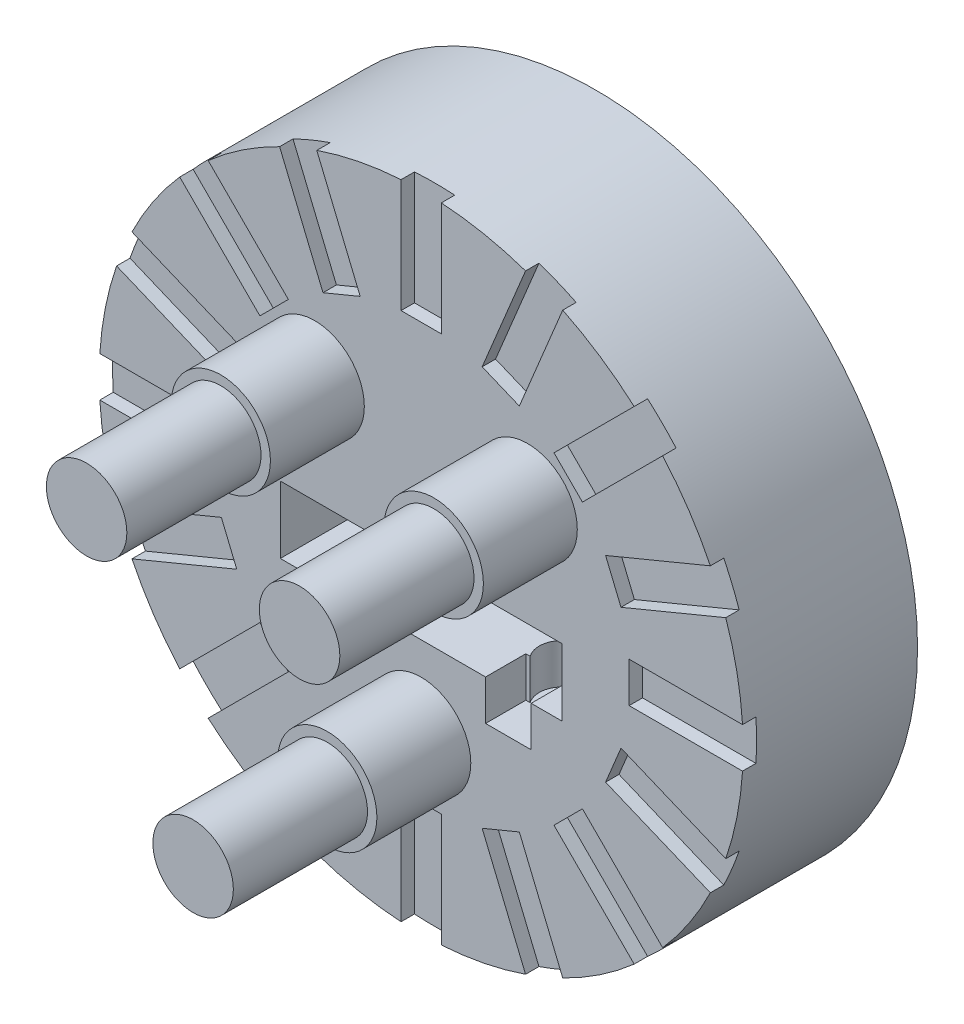
from build123d import *

# Parameters (mm, degrees)
SKETCH1_R           = 24
EXTRUDE1_DEPTH      = 5
SKETCH2_R           = 24
EXTRUDE2_DEPTH      = 8
SKETCH3_R           = 2.5
SKETCH3_R_2         = 3.7
EXTRUDE3_DEPTH      = 7
SKETCH5_R           = 3
EXTRUDE6_DEPTH      = 10
SKETCH6_R           = 3.175
EXTRUDE7_DEPTH      = 3
SKETCH7_R           = 1.7
EXTRUDE8_DEPTH      = 8
EXTRUDE8_DEPTH_BACK = 3
SKETCH8_W           = 3.4
SKETCH8_H           = 3
EXTRUDE9_DEPTH      = 3
EXTRUDE10_DEPTH     = 1


with BuildPart() as part:
    # Sketch1 → Extrude1 (new body)
    with BuildSketch(Plane.XY):
        Circle(SKETCH1_R)
    extrude(amount=EXTRUDE1_DEPTH)

    # Sketch2 → Extrude2 (add)
    with BuildSketch(Plane.XY.offset(5)):
        Circle(SKETCH2_R)
        with BuildLine():
            Line((-2.5, 0), (-10.5, 0))
            Line((-10.5, 0), (-10.5, -5))
            Line((-10.5, -5), (10.5, -5))
            Line((10.5, -5), (10.5, 0))
            Line((10.5, 0), (2.5, 0))
            ThreePointArc((2.5, 0), (0, -2.5), (-2.5, 0))
        make_face(mode=Mode.SUBTRACT)
    extrude(amount=EXTRUDE2_DEPTH)

    # Sketch3 → Extrude3 (add)
    with BuildSketch(Plane.XY.offset(13)):
        Circle(SKETCH3_R)
        with Locations((-7.9375, 7.9375)):
            Circle(SKETCH3_R_2)
        with Locations((7.9375, 7.9375)):
            Circle(SKETCH3_R_2)
        with Locations((0, -11.1125)):
            Circle(SKETCH3_R_2)
    extrude(amount=EXTRUDE3_DEPTH)

    # Sketch5 → Extrude6 (add)
    with BuildSketch(Plane.XY.offset(20)):
        with Locations((-7.9375, 7.9375)):
            Circle(SKETCH5_R)
        with Locations((7.9375, 7.9375)):
            Circle(SKETCH5_R)
        with Locations((0, -11.1125)):
            Circle(SKETCH5_R)
    extrude(amount=EXTRUDE6_DEPTH)

    # Sketch6 → Extrude7 (cut)
    with BuildSketch(Plane(origin=(0, 0, 0), x_dir=(-1, 0, 0), z_dir=(0, 0, -1))):
        with Locations((0, 12.7)):
            Circle(SKETCH6_R)
        with Locations((7.9375, -11.1125)):
            Circle(SKETCH6_R)
        with Locations((-7.9375, -11.1125)):
            Circle(SKETCH6_R)
    extrude(amount=-EXTRUDE7_DEPTH, mode=Mode.SUBTRACT)

    # Sketch7 → Extrude8 (cut, two sides)
    with BuildSketch(Plane.XZ) as extrude8_sk:
        with Locations((-6.5, 9)):
            Circle(SKETCH7_R)
        with Locations((6.5, 9)):
            Circle(SKETCH7_R)
    extrude(amount=EXTRUDE8_DEPTH, mode=Mode.SUBTRACT)
    extrude(extrude8_sk.sketch, amount=-EXTRUDE8_DEPTH_BACK, mode=Mode.SUBTRACT)

    # Sketch8 → Extrude9 (cut)
    with BuildSketch(Plane.XY.offset(13)):
        with Locations((-6.5, -6.5)):
            Rectangle(SKETCH8_W, SKETCH8_H)
        with Locations((6.5, -6.5)):
            Rectangle(SKETCH8_W, SKETCH8_H)
    extrude(amount=-EXTRUDE9_DEPTH, mode=Mode.SUBTRACT)

    # Sketch9 → Extrude10 (cut)
    with BuildSketch(Plane.XY.offset(13)):
        Polygon((24, 0), (24, -1.5), (15.5, -1.5), (15.5, 1.5), (24, 1.5), align=None)
        Polygon((22.17310878, 9.184402377), (22.747133929, 7.798583078), (14.894157902, 4.545773903), (13.746107605, 7.3174125), (21.599083632, 10.570221676), align=None)
        Polygon((16.970562748, 16.970562748), (18.03122292, 15.909902577), (12.02081528, 9.899494937), (9.899494937, 12.02081528), (15.909902577, 18.03122292), align=None)
        Polygon((9.184402377, 22.17310878), (10.570221676, 21.599083632), (7.3174125, 13.746107605), (4.545773903, 14.894157902), (7.798583078, 22.747133929), align=None)
        Polygon((0, 24), (1.5, 24), (1.5, 15.5), (-1.5, 15.5), (-1.5, 24), align=None)
        Polygon((-9.184402377, 22.17310878), (-7.798583078, 22.747133929), (-4.545773903, 14.894157902), (-7.3174125, 13.746107605), (-10.570221676, 21.599083632), align=None)
        Polygon((-16.970562748, 16.970562748), (-15.909902577, 18.03122292), (-9.899494937, 12.02081528), (-12.02081528, 9.899494937), (-18.03122292, 15.909902577), align=None)
        Polygon((-22.17310878, 9.184402377), (-21.599083632, 10.570221676), (-13.746107605, 7.3174125), (-14.894157902, 4.545773903), (-22.747133929, 7.798583078), align=None)
        Polygon((-24, 0), (-24, 1.5), (-15.5, 1.5), (-15.5, -1.5), (-24, -1.5), align=None)
        Polygon((-22.17310878, -9.184402377), (-22.747133929, -7.798583078), (-14.894157902, -4.545773903), (-13.746107605, -7.3174125), (-21.599083632, -10.570221676), align=None)
        Polygon((-16.970562748, -16.970562748), (-15.909902577, -18.03122292), (-9.899494937, -12.02081528), (-12.02081528, -9.899494937), (-18.03122292, -15.909902577), align=None)
        Polygon((-9.184402377, -22.17310878), (-7.798583078, -22.747133929), (-4.545773903, -14.894157902), (-7.3174125, -13.746107605), (-10.570221676, -21.599083632), align=None)
        Polygon((0, -24), (1.5, -24), (1.5, -15.5), (-1.5, -15.5), (-1.5, -24), align=None)
        Polygon((9.184402377, -22.17310878), (10.570221676, -21.599083632), (7.3174125, -13.746107605), (4.545773903, -14.894157902), (7.798583078, -22.747133929), align=None)
        Polygon((16.970562748, -16.970562748), (18.03122292, -15.909902577), (12.02081528, -9.899494937), (9.899494937, -12.02081528), (15.909902577, -18.03122292), align=None)
        Polygon((22.17310878, -9.184402377), (22.747133929, -7.798583078), (14.894157902, -4.545773903), (13.746107605, -7.3174125), (21.599083632, -10.570221676), align=None)
    extrude(amount=-EXTRUDE10_DEPTH, mode=Mode.SUBTRACT)


solid = part.part
